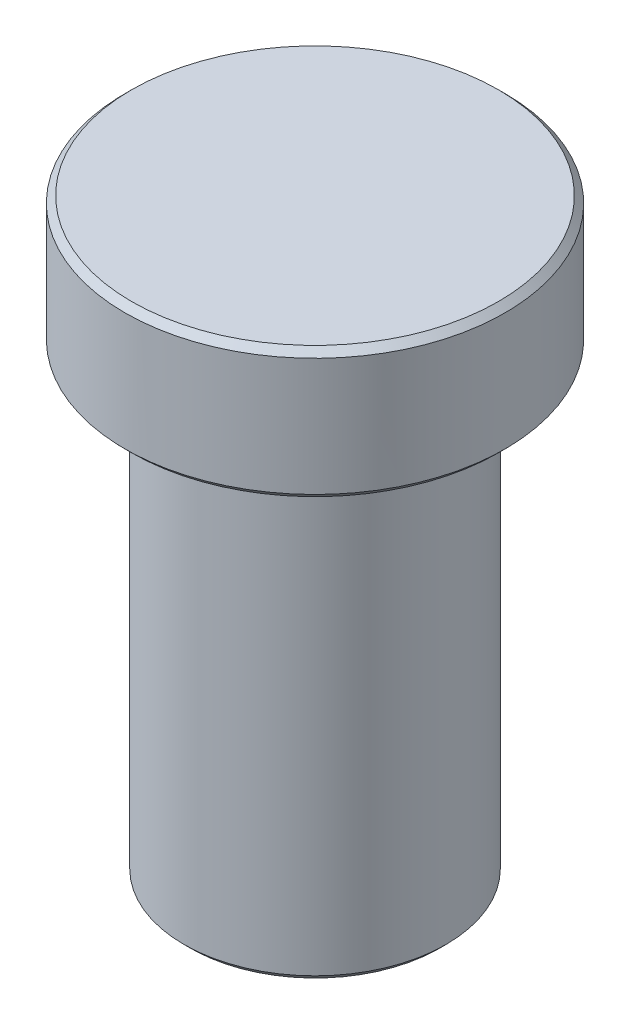
from build123d import *

# Parameters (mm, degrees)
CHAMFER1_SIZE = 0.1


with BuildPart() as part:
    # Sketch1 → Revolve1 (revolve)
    with BuildSketch(Plane.XY):
        Polygon((0, 0), (0, 9), (2.9, 9), (2.9, 7), (2, 7), (2, 0), align=None)
    revolve(axis=Axis((0, 0, 0), (0, 1, 0)))

    # Chamfer1
    chamfer1_edges = [part.edges().sort_by_distance(p)[0] for p in [
        (-2, 0, 0),
        (-2.9, 7, 0),
        (-2.9, 9, 0),
    ]]
    chamfer(chamfer1_edges, length=CHAMFER1_SIZE)


solid = part.part
